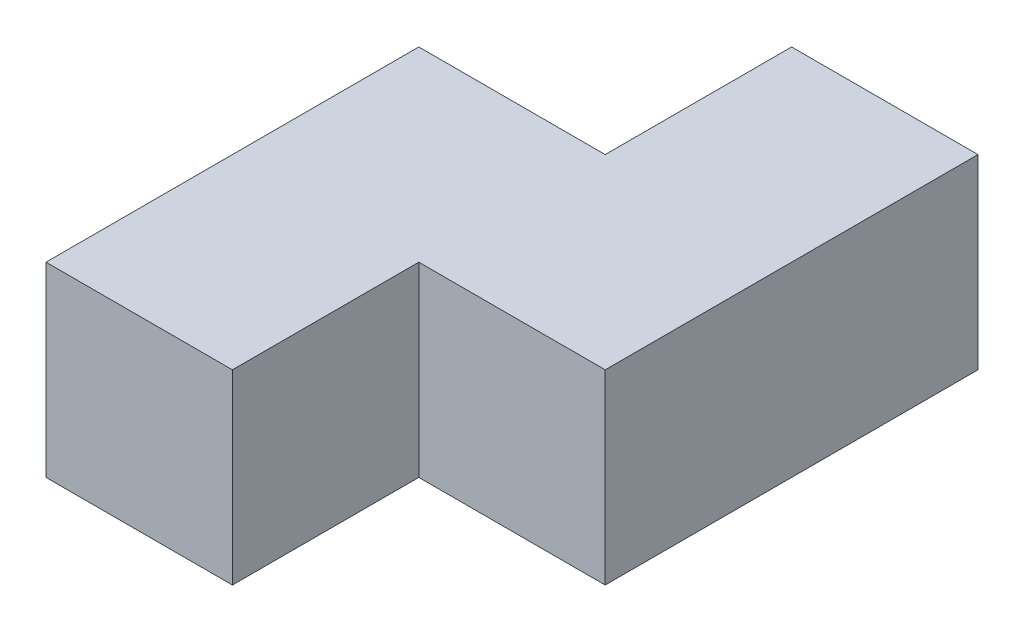
from build123d import *

# Parameters (mm, degrees)
BOSS_EXTRUDE1_DEPTH = 5000


with BuildPart() as part:
    # Sketch1 → Boss-Extrude1 (new body)
    with BuildSketch(Plane(origin=(0, 0, 0), x_dir=(1, 0, 0), z_dir=(0, 1, 0))):
        Polygon((0, 7500), (0, 2500), (-5000, 2500), (-5000, -7500), (0, -7500), (0, -2500), (5000, -2500), (5000, 7500), align=None)
    extrude(amount=BOSS_EXTRUDE1_DEPTH)


solid = part.part
